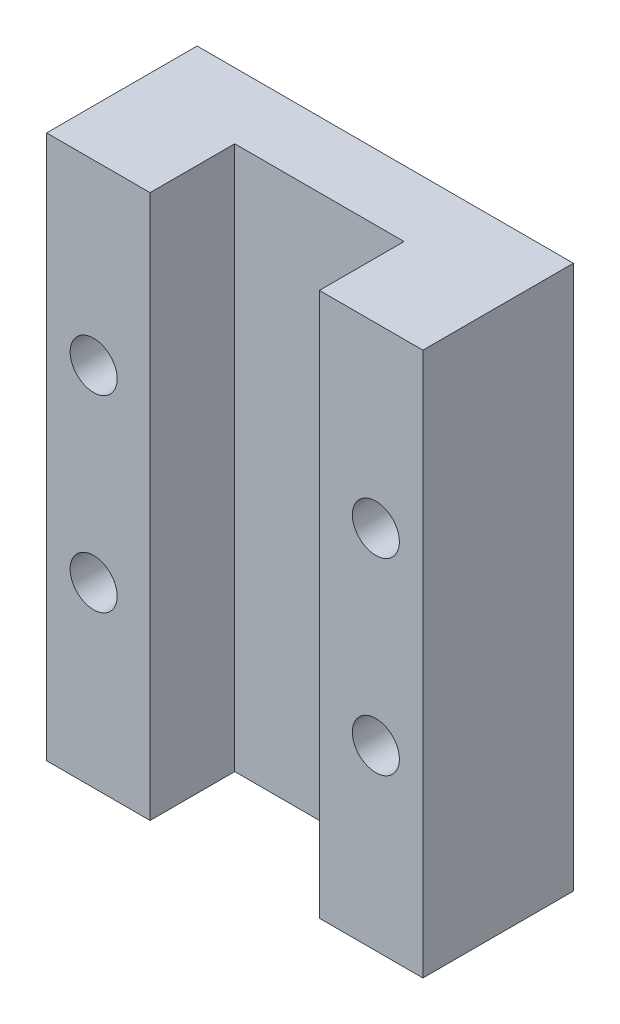
from build123d import *

# Parameters (mm, degrees)
SKETCH_1_W             = 20
SKETCH_1_H             = 28.9
EXTRUDE_1_DEPTH        = 8
SKETCH_2_W             = 9
SKETCH_2_H             = 4.5
CUT_EXTRUDE_1_DEPTH    = 29.9
HOLE_WIZARD_M3_1_D     = 2.5
HOLE_WIZARD_M3_1_DEPTH = 10.1
HOLE_WIZARD_M3_1_TIP   = 0.751075774


with BuildPart() as part:
    # 草图1 → 凸台-拉伸1 (new body)
    with BuildSketch(Plane.XY):
        with Locations((10, 14.45)):
            Rectangle(SKETCH_1_W, SKETCH_1_H)
    extrude(amount=EXTRUDE_1_DEPTH)

    # 草图2 → 切除-拉伸1 (cut, through all)
    with BuildSketch(Plane(origin=(0, 28.9, 0), x_dir=(1, 0, 0), z_dir=(0, 1, 0))):
        with Locations((10, -5.75)):
            Rectangle(SKETCH_2_W, SKETCH_2_H)
    extrude(amount=-CUT_EXTRUDE_1_DEPTH, mode=Mode.SUBTRACT)

    # M3 螺纹孔1
    with Locations(Plane(origin=(0, 0, 0), x_dir=(-1, 0, 0), z_dir=(0, 0, -1))):
        with Locations((-2.5, 9.45), (-17.5, 9.45), (-2.5, 19.45), (-17.5, 19.45)):
            Hole(HOLE_WIZARD_M3_1_D / 2, depth=HOLE_WIZARD_M3_1_DEPTH)
            with Locations((0, 0, -(HOLE_WIZARD_M3_1_DEPTH + HOLE_WIZARD_M3_1_TIP / 2))):  # 118° drill point
                Cone(0, HOLE_WIZARD_M3_1_D / 2, HOLE_WIZARD_M3_1_TIP, mode=Mode.SUBTRACT)


solid = part.part
